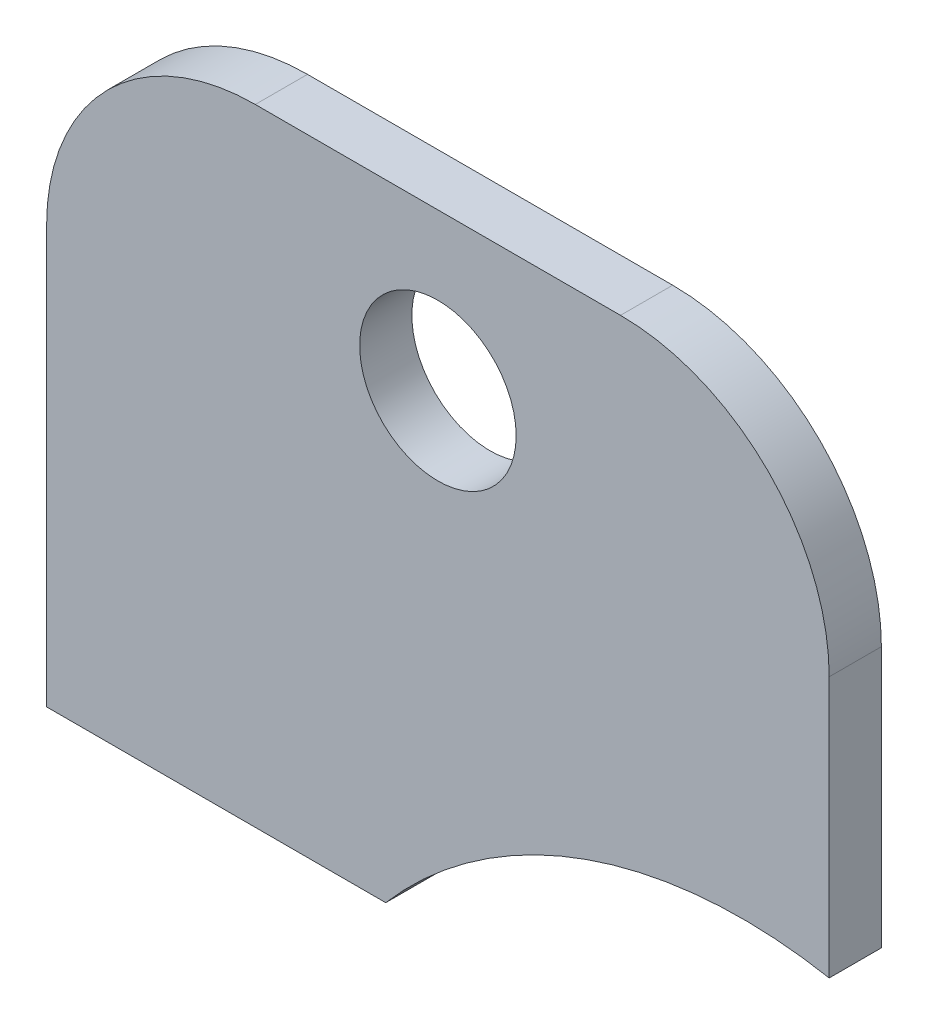
from build123d import *

# Parameters (mm, degrees)
DODANIE_WYCI_GNI_CIE2_DEPTH = 2
SZKIC4_R                    = 3
WYTNIJ_WYCI_GNI_CIE2_DEPTH  = 2
ZAOKR_GLENIE1_R             = 8
ZAOKR_GLENIE2_R             = 8


with BuildPart() as part:
    # Szkic3 → Dodanie-wyciągnięcie2 (new body)
    with BuildSketch(Plane.XY):
        with BuildLine():
            Line((1470.717856821, -27.5), (1500.717856821, -27.5))
            Line((1500.717856821, -27.5), (1500.717856821, -45.5))
            ThreePointArc((1500.717856821, -45.5), (1491.412577396, -46.218374962), (1483.717856821, -51.5))
            Line((1483.717856821, -51.5), (1470.717856821, -51.5))
            Line((1470.717856821, -51.5), (1470.717856821, -27.5))
        make_face()
    extrude(amount=DODANIE_WYCI_GNI_CIE2_DEPTH)

    # Szkic4 → Wytnij-wyciągnięcie2 (cut)
    with BuildSketch(Plane.XY.offset(2)):
        with Locations((1485.717856821, -33.5)):
            Circle(SZKIC4_R)
    extrude(amount=-WYTNIJ_WYCI_GNI_CIE2_DEPTH, mode=Mode.SUBTRACT)

    # Zaokrąglenie1
    zaokr_glenie1_edges = [part.edges().sort_by_distance(p)[0] for p in [
        (1470.717856821, -27.5, 1),
    ]]
    fillet(zaokr_glenie1_edges, radius=ZAOKR_GLENIE1_R)

    # Zaokrąglenie2
    zaokr_glenie2_edges = [part.edges().sort_by_distance(p)[0] for p in [
        (1500.717856821, -27.5, 1),
    ]]
    fillet(zaokr_glenie2_edges, radius=ZAOKR_GLENIE2_R)


solid = part.part
